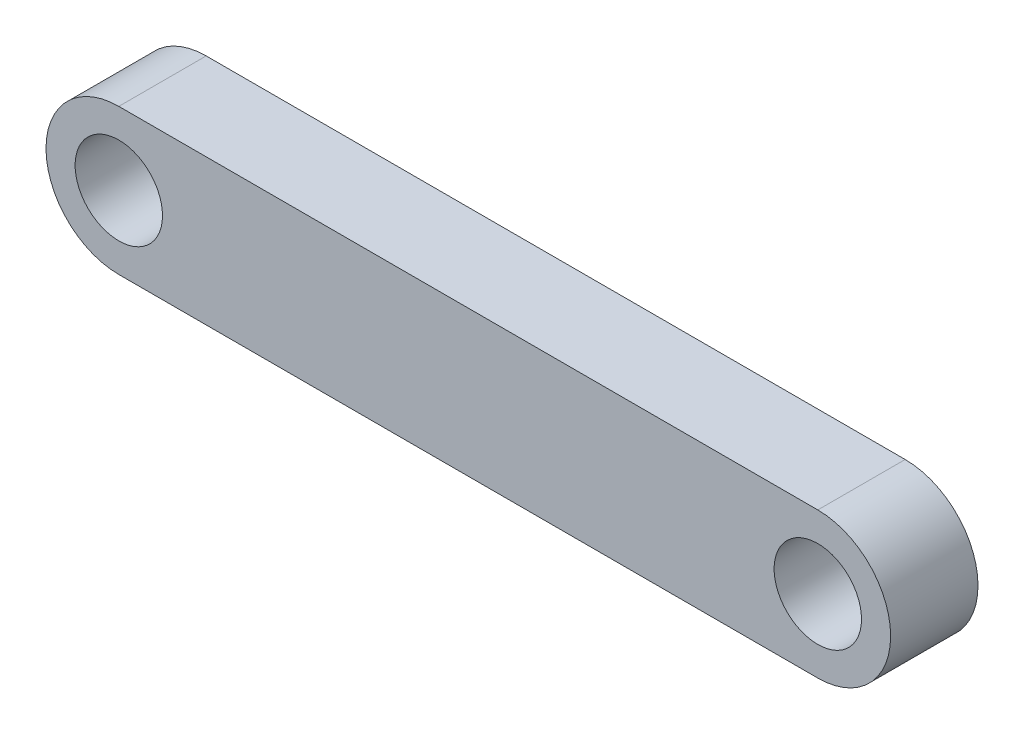
from build123d import *

# Parameters (mm, degrees)
SKETCH1_R           = 3
BOSS_EXTRUDE1_DEPTH = 6


with BuildPart() as part:
    # Sketch1 → Boss-Extrude1 (new body)
    with BuildSketch(Plane.XY):
        with BuildLine():
            ThreePointArc((0, 5), (-5, 0), (0, -5))
            Line((0, -5), (48, -5))
            ThreePointArc((48, -5), (53, 0), (48, 5))
            Line((48, 5), (0, 5))
        make_face()
        Circle(SKETCH1_R, mode=Mode.SUBTRACT)
        with Locations((48, 0)):
            Circle(SKETCH1_R, mode=Mode.SUBTRACT)
    extrude(amount=BOSS_EXTRUDE1_DEPTH)


solid = part.part
